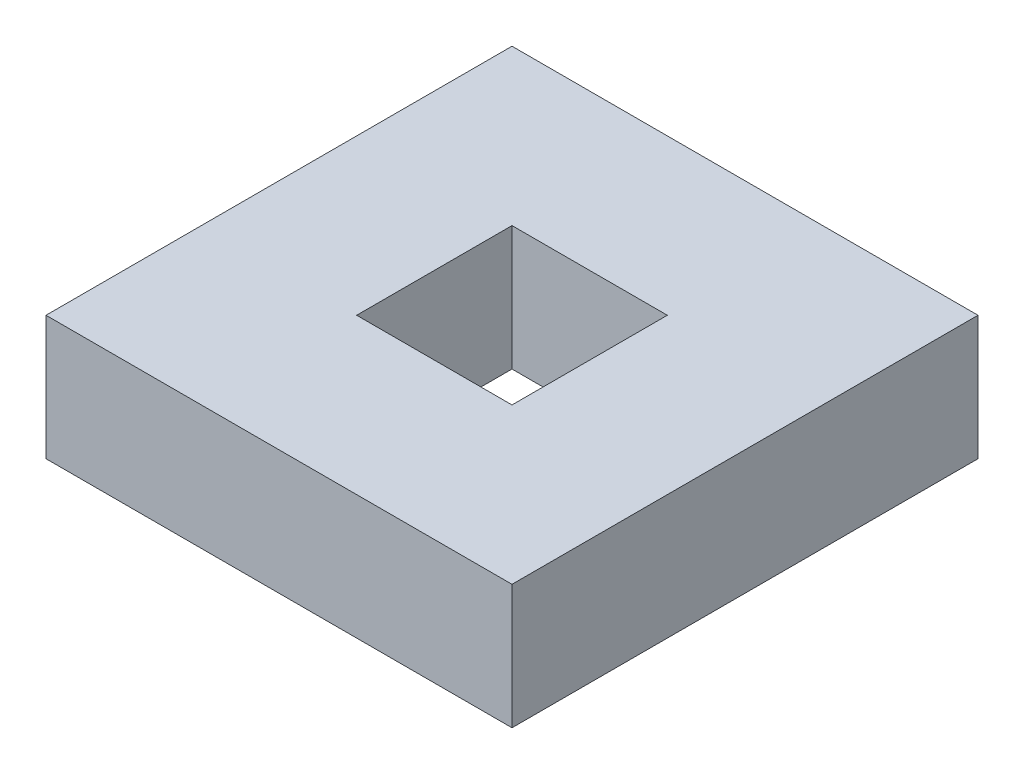
from build123d import *

# Parameters (mm, degrees)
SKETCH1_W           = 3
SKETCH1_H           = 3
BOSS_EXTRUDE1_DEPTH = 0.8
SKETCH2_W           = 1
SKETCH2_H           = 1
CUT_EXTRUDE1_DEPTH  = 1.6


with BuildPart() as part:
    # Sketch1 → Boss-Extrude1 (new body)
    with BuildSketch(Plane(origin=(0, 0, 0), x_dir=(1, 0, 0), z_dir=(0, 1, 0))):
        with Locations((1.5, 1.5)):
            Rectangle(SKETCH1_W, SKETCH1_H)
    extrude(amount=BOSS_EXTRUDE1_DEPTH)

    # Sketch2 → Cut-Extrude1 (cut)
    with BuildSketch(Plane(origin=(0, 0.8, 0), x_dir=(1, 0, 0), z_dir=(0, 1, 0))):
        with Locations((1.5, 1.5)):
            Rectangle(SKETCH2_W, SKETCH2_H)
    extrude(amount=-CUT_EXTRUDE1_DEPTH, mode=Mode.SUBTRACT)


solid = part.part
